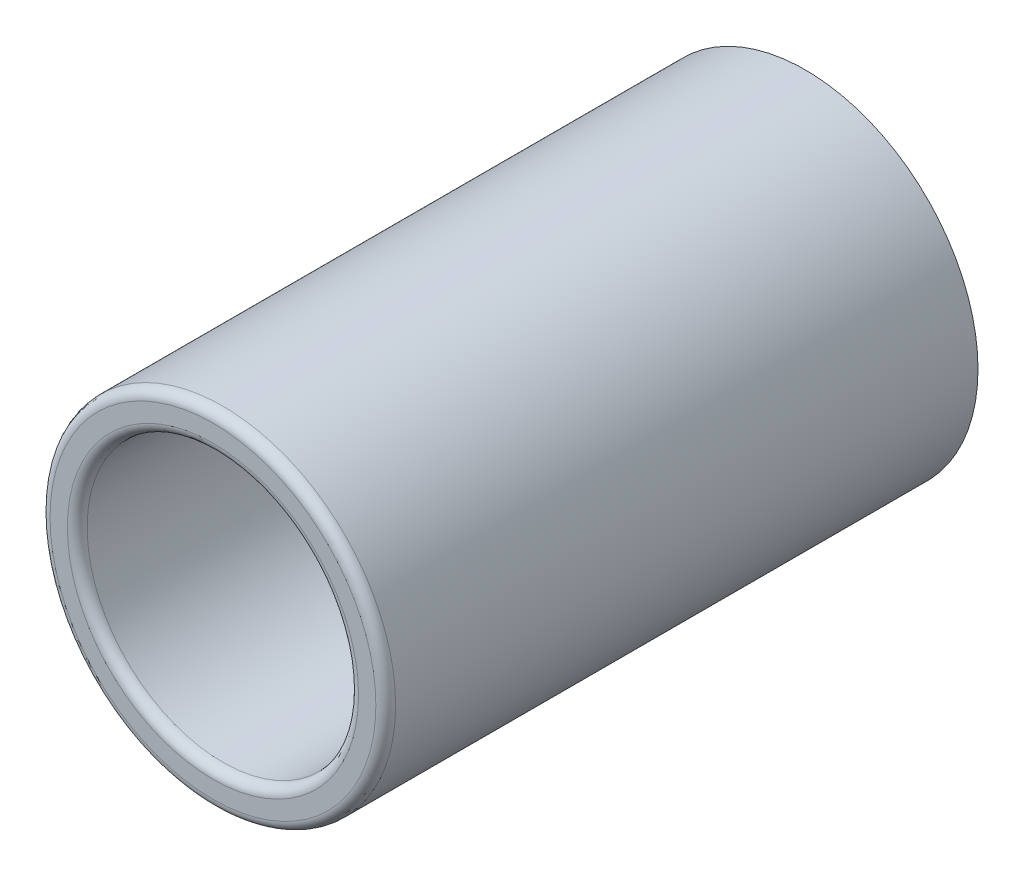
from build123d import *

# Parameters (mm, degrees)
SKETCH1_R           = 3.5
SKETCH1_R_2         = 2.75
BOSS_EXTRUDE1_DEPTH = 12
FILLET1_R           = 0.2


with BuildPart() as part:
    # Sketch1 → Boss-Extrude1 (new body)
    with BuildSketch(Plane.XY):
        Circle(SKETCH1_R)
        Circle(SKETCH1_R_2, mode=Mode.SUBTRACT)
    extrude(amount=BOSS_EXTRUDE1_DEPTH)

    # Fillet1
    fillet1_edges = [part.edges().sort_by_distance(p)[0] for p in [
        (-3.5, 0, 12),
        (-2.75, 0, 12),
    ]]
    fillet(fillet1_edges, radius=FILLET1_R)


solid = part.part
